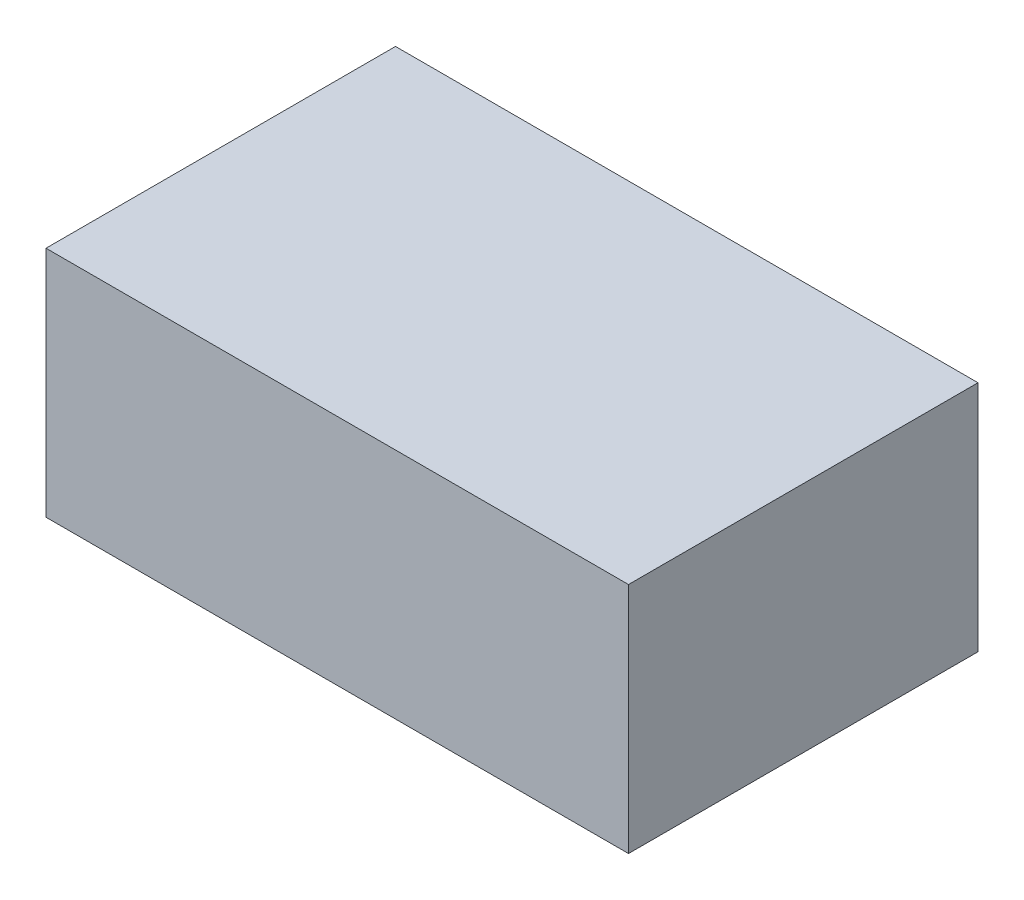
from build123d import *

# Parameters (mm, degrees)
SKETCH1_W           = 31.75
SKETCH1_H           = 12.7
BOSS_EXTRUDE1_DEPTH = 19.05


with BuildPart() as part:
    # Sketch1 → Boss-Extrude1 (new body)
    with BuildSketch(Plane.XY):
        Rectangle(SKETCH1_W, SKETCH1_H)
    extrude(amount=BOSS_EXTRUDE1_DEPTH)


solid = part.part
